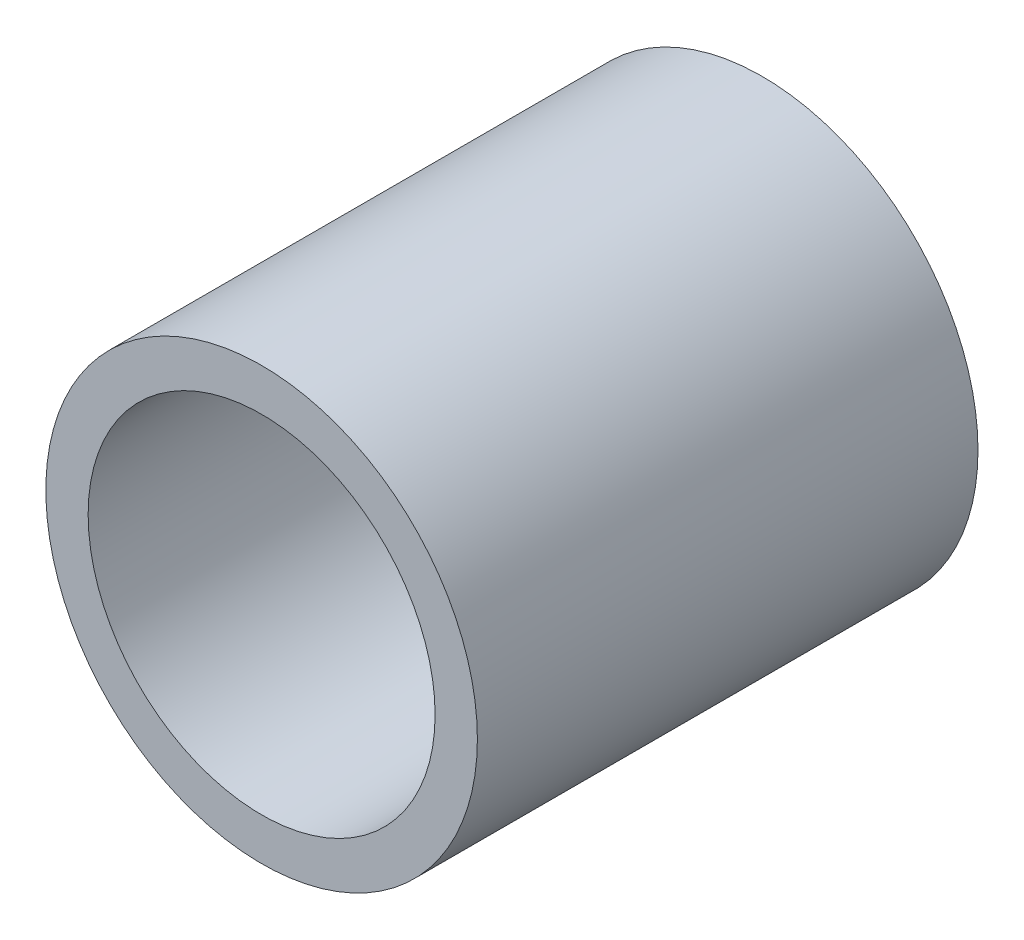
from build123d import *

# Parameters (mm, degrees)
SKETCH3_R           = 6.35
SKETCH3_R_2         = 5.1054
BOSS_EXTRUDE1_DEPTH = 7.366


with BuildPart() as part:
    # Sketch3 → Boss-Extrude1 (new, symmetric)
    with BuildSketch(Plane.XY):
        Circle(SKETCH3_R)
        Circle(SKETCH3_R_2, mode=Mode.SUBTRACT)
    extrude(amount=BOSS_EXTRUDE1_DEPTH, both=True)


solid = part.part
